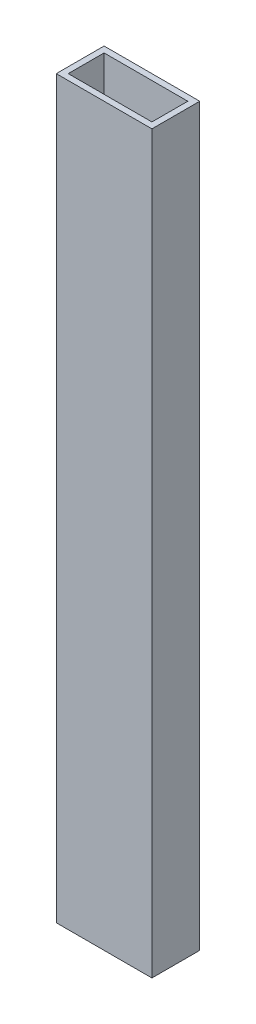
from build123d import *

# Parameters (mm, degrees)
SKETCH1_W           = 50.8
SKETCH1_H           = 25.4
SKETCH1_W_2         = 44.45
SKETCH1_H_2         = 19.05
BOSS_EXTRUDE1_DEPTH = 390.525


with BuildPart() as part:
    # Sketch1 → Boss-Extrude1 (new body)
    with BuildSketch(Plane(origin=(0, 0, 0), x_dir=(1, 0, 0), z_dir=(0, 1, 0))):
        with Locations((25.4, 12.7)):
            Rectangle(SKETCH1_W, SKETCH1_H)
        with Locations((25.4, 12.7)):
            Rectangle(SKETCH1_W_2, SKETCH1_H_2, mode=Mode.SUBTRACT)
    extrude(amount=BOSS_EXTRUDE1_DEPTH)


solid = part.part
